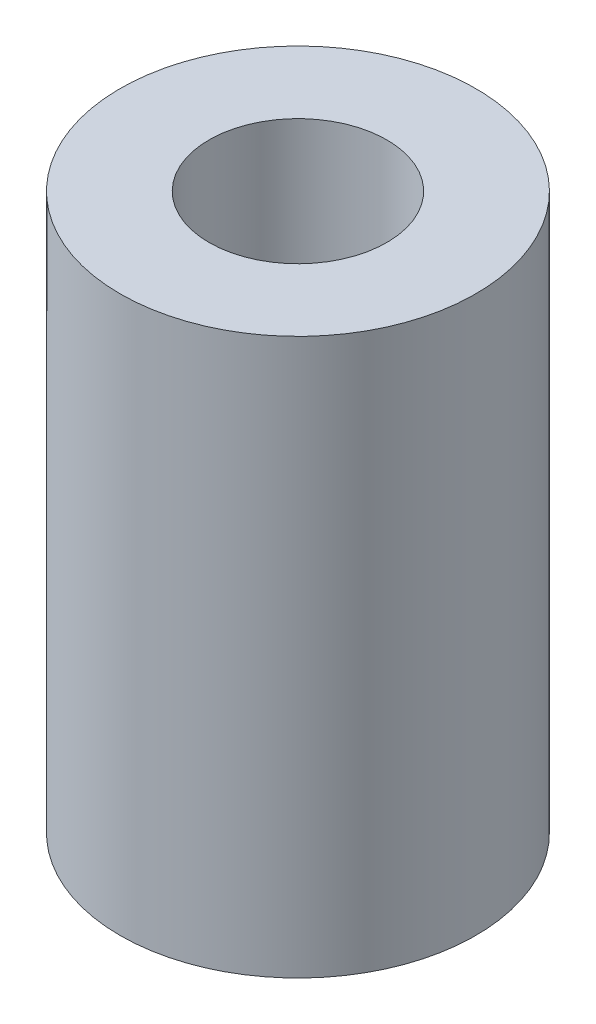
from build123d import *

# Parameters (mm, degrees)
SKETCH1_R           = 8
SKETCH1_R_2         = 4
BOSS_EXTRUDE1_DEPTH = 25


with BuildPart() as part:
    # Sketch1 → Boss-Extrude1 (new body)
    with BuildSketch(Plane(origin=(0, 0, 0), x_dir=(1, 0, 0), z_dir=(0, 1, 0))):
        with Locations(Location((0, 0, 0), (0, 0, 270))):  # turned: the seam where the file's is
            Circle(SKETCH1_R)
        with Locations(Location((0, 0, 0), (0, 0, 270))):  # turned: the seam where the file's is
            Circle(SKETCH1_R_2, mode=Mode.SUBTRACT)
    extrude(amount=BOSS_EXTRUDE1_DEPTH)


solid = part.part
